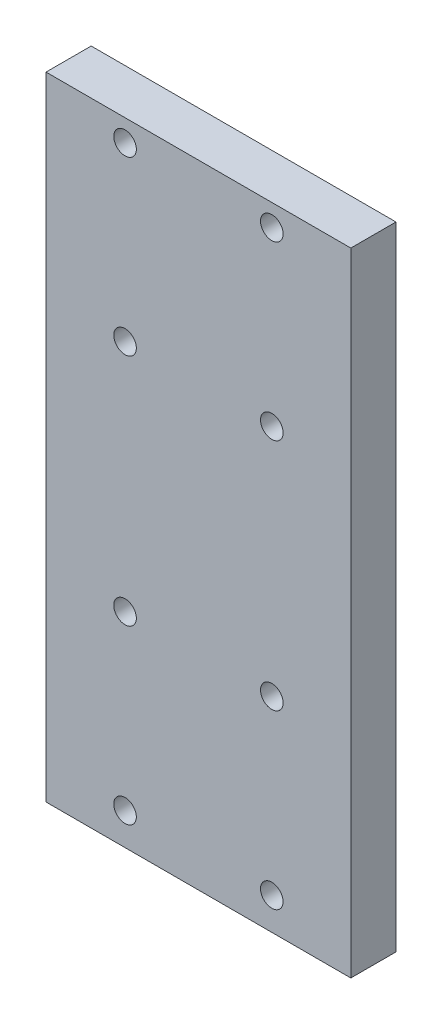
from build123d import *

# Parameters (mm, degrees)
SKETCH1_W           = 54
SKETCH1_H           = 112
SKETCH1_R           = 2
BOSS_EXTRUDE1_DEPTH = 8


with BuildPart() as part:
    # Sketch1 → Boss-Extrude1 (new body)
    with BuildSketch(Plane.XY):
        Rectangle(SKETCH1_W, SKETCH1_H)
        with Locations((-13, 52.14)):
            Circle(SKETCH1_R, mode=Mode.SUBTRACT)
        with Locations((13, 52.14)):
            Circle(SKETCH1_R, mode=Mode.SUBTRACT)
        with Locations((13, 21.64)):
            Circle(SKETCH1_R, mode=Mode.SUBTRACT)
        with Locations((-13, 21.64)):
            Circle(SKETCH1_R, mode=Mode.SUBTRACT)
        with Locations((13, -19.8)):
            Circle(SKETCH1_R, mode=Mode.SUBTRACT)
        with Locations((-13, -19.8)):
            Circle(SKETCH1_R, mode=Mode.SUBTRACT)
        with Locations((-13, -50.3)):
            Circle(SKETCH1_R, mode=Mode.SUBTRACT)
        with Locations((13, -50.3)):
            Circle(SKETCH1_R, mode=Mode.SUBTRACT)
    extrude(amount=BOSS_EXTRUDE1_DEPTH)


solid = part.part
